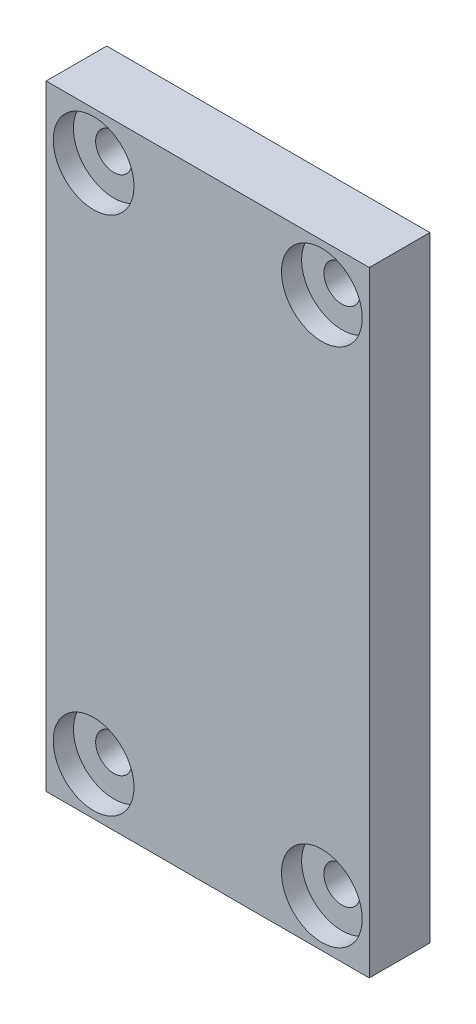
from build123d import *

# Parameters (mm, degrees)
SKETCH1_W           = 16.006506223
SKETCH1_H           = 30.48
SKETCH1_R           = 0.899999978
BOSS_EXTRUDE1_DEPTH = 3
SKETCH2_R           = 2.000000064
CUT_EXTRUDE1_DEPTH  = 1


with BuildPart() as part:
    # Sketch1 → Boss-Extrude1 (new body)
    with BuildSketch(Plane.XY):
        with Locations((17.570669053, 0)):
            Rectangle(SKETCH1_W, SKETCH1_H)
        with Locations((11.917415941, 12.89)):
            Circle(SKETCH1_R, mode=Mode.SUBTRACT)
        with Locations((23.223922164, 12.89)):
            Circle(SKETCH1_R, mode=Mode.SUBTRACT)
        with Locations((23.223922164, -12.89)):
            Circle(SKETCH1_R, mode=Mode.SUBTRACT)
        with Locations((11.917415941, -12.89)):
            Circle(SKETCH1_R, mode=Mode.SUBTRACT)
    extrude(amount=BOSS_EXTRUDE1_DEPTH)

    # Sketch2 → Cut-Extrude1 (cut)
    with BuildSketch(Plane.XY.offset(3)):
        with Locations((23.223922164, 12.89)):
            Circle(SKETCH2_R)
        with Locations((23.223922164, -12.89)):
            Circle(SKETCH2_R)
        with Locations((11.917415941, -12.89)):
            Circle(SKETCH2_R)
        with Locations((11.917415941, 12.89)):
            Circle(SKETCH2_R)
    extrude(amount=-CUT_EXTRUDE1_DEPTH, mode=Mode.SUBTRACT)


solid = part.part
